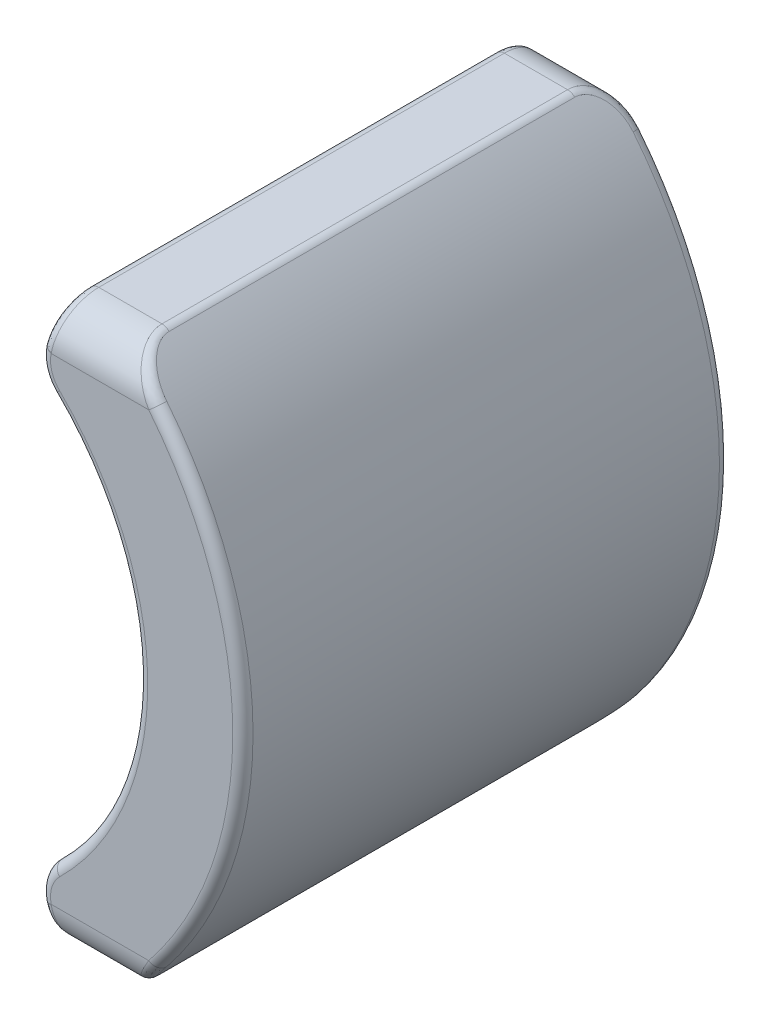
from build123d import *

# Parameters (mm, degrees)
BOSS_EXTRUDE1_DEPTH = 12
FILLET1_R           = 1
FILLET2_R           = 1
FILLET3_R           = 0.25


with BuildPart() as part:
    # Sketch1 → Boss-Extrude1 (new body)
    with BuildSketch(Plane.XY):
        with BuildLine():
            Line((6.738137725, -6.88), (4.878137725, -6.88))
            Line((4.878137725, -6.88), (4.531835438, -5.38))
            ThreePointArc((4.531835438, -5.38), (7.034339517, 0), (4.531835438, 5.38))
            Line((4.531835438, 5.38), (4.878137725, 6.88))
            Line((4.878137725, 6.88), (6.738137725, 6.88))
            ThreePointArc((6.738137725, 6.88), (9.63, 0), (6.738137725, -6.88))
        make_face()
    extrude(amount=BOSS_EXTRUDE1_DEPTH)

    # Fillet1
    fillet1_edges = [part.edges().sort_by_distance(p)[0] for p in [
        (4.531835438, -5.38, 6),
        (4.531835438, 5.38, 6),
    ]]
    fillet(fillet1_edges, radius=FILLET1_R)

    # Fillet2
    fillet2_edges = [part.edges().sort_by_distance(p)[0] for p in [
        (5.808137725, -6.88, 0),
        (5.808137725, 6.88, 0),
        (5.808137725, -6.88, 12),
        (5.808137725, 6.88, 12),
    ]]
    fillet(fillet2_edges, radius=FILLET2_R)

    # Fillet3
    fillet3_edges = [part.edges().sort_by_distance(p)[0] for p in [
        (7.034339517, 0, 0),
        (4.687877266, 5.411310183, 0),
        (7.034339517, 0, 12),
        (4.687877266, -5.411310183, 12),
        (6.738137725, -6.88, 6),
        (4.878137725, -6.88, 6),
        (9.63, 0, 0),
        (6.738137725, 6.88, 6),
        (9.63, 0, 12),
        (7.064336577, 6.544619807, 11.7471817),
        (7.064336589, -6.544619821, 11.747181705),
        (7.064336577, 6.544619807, 0.2528183),
        (7.064336577, -6.544619807, 0.2528183),
        (4.687877266, -5.411310183, 0),
        (4.655934772, -5.914769545, 11.999395357),
        (4.655934772, -5.914769545, 0.000604643),
        (4.815123489, -6.607055355, 11.686578845),
        (4.815123489, -6.607055355, 0.313421155),
        (4.878137725, 6.88, 6),
        (4.815123489, 6.607055355, 11.686578845),
        (4.815123489, 6.607055355, 0.313421155),
        (4.687877266, 5.411310183, 12),
        (4.655934776, 5.914769544, 11.99939535),
        (4.655934776, 5.914769544, 0.00060465),
    ]]
    fillet(fillet3_edges, radius=FILLET3_R)


solid = part.part
